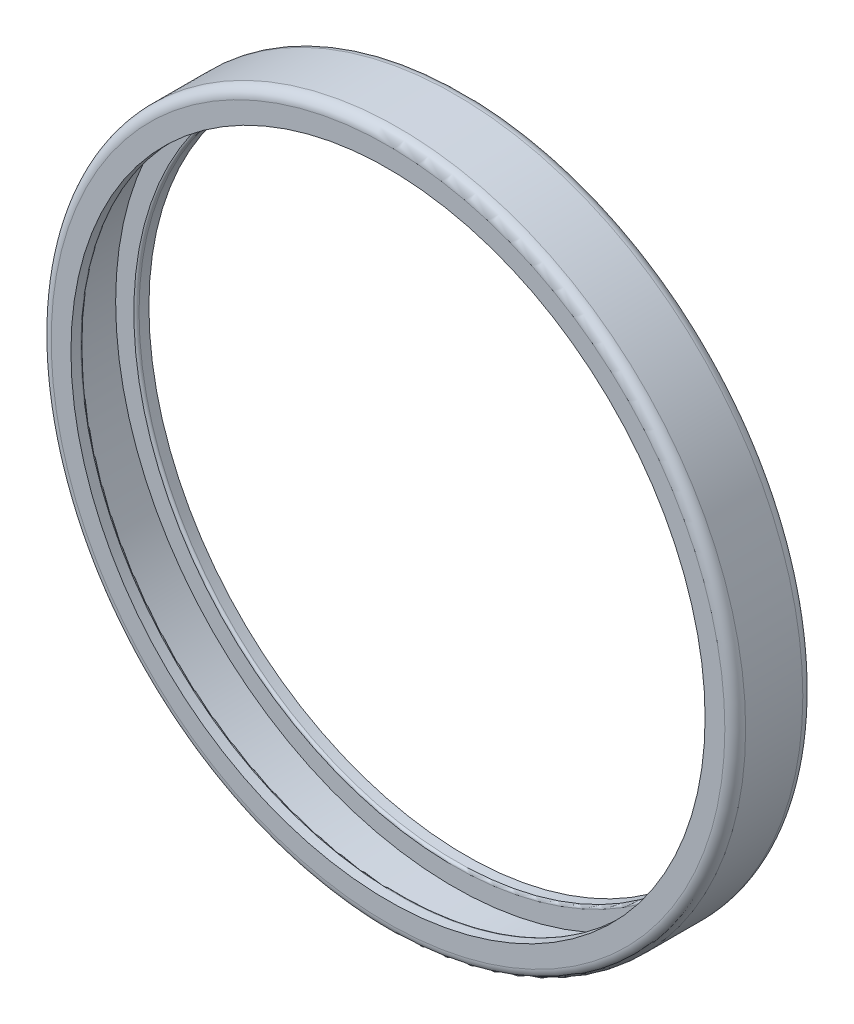
from build123d import *

# Parameters (mm, degrees)
FILLET2_R = 0.25
FILLET3_R = 1


with BuildPart() as part:
    # Sketch1 → Revolve1 (revolve)
    with BuildSketch(Plane(origin=(0, 0, 0), x_dir=(0, 0, -1), z_dir=(1, 0, 0)), mode=Mode.PRIVATE) as revolve1_sk:
        Polygon((-3.75, 33.4), (3.75, 33.4), (3.75, 30.5), (2.55, 30.5), (2.55, 32.5), (-2.55, 32.5), (-2.55, 30.5), (-3.75, 30.5), align=None)
    revolve(revolve1_sk.sketch.rotate(Axis((0, 0, -25), (0, 0, 1)), 90), axis=Axis((0, 0, -25), (0, 0, 1)))  # turned: the seam where the file's is

    # Fillet2
    fillet2_edges = [part.edges().sort_by_distance(p)[0] for p in [
        (30.5, 0, -2.55),
        (30.5, 0, 2.55),
    ]]
    fillet(fillet2_edges, radius=FILLET2_R)

    # Fillet3
    fillet3_edges = [part.edges().sort_by_distance(p)[0] for p in [
        (33.4, 0, 3.75),
        (33.4, 0, -3.75),
    ]]
    fillet(fillet3_edges, radius=FILLET3_R)


solid = part.part
